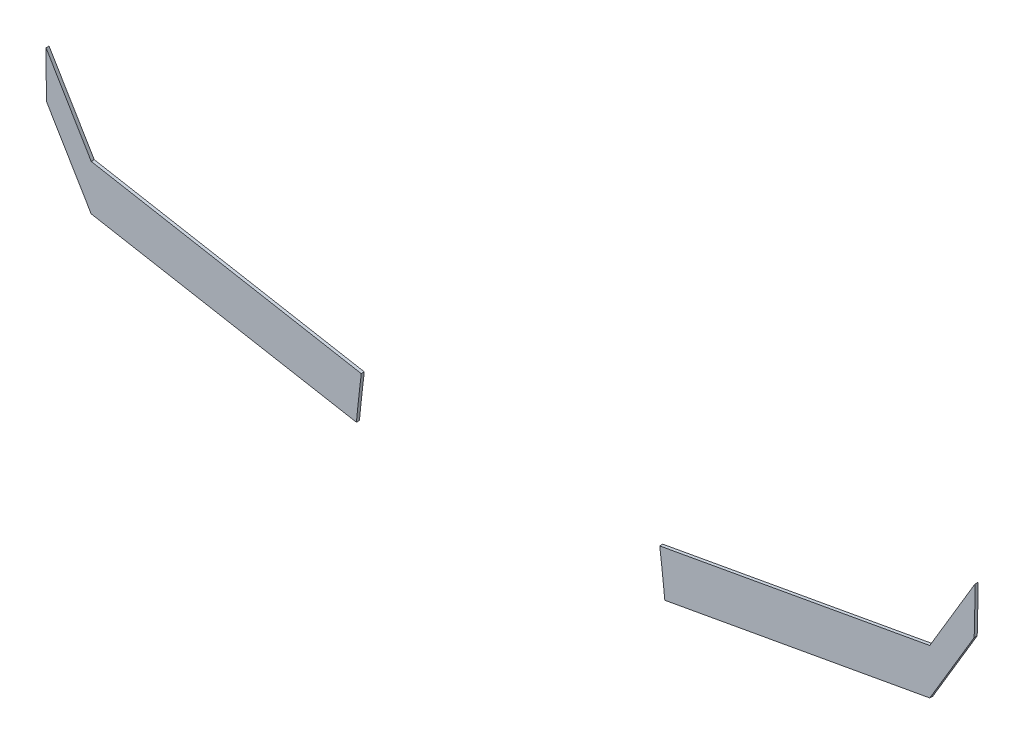
from build123d import *

# Parameters (mm, degrees)
SALIENTE_EXTRUIR1_DEPTH   = 0.1
SALIENTE_EXTRUIR1_2_DEPTH = 0.1


with BuildPart() as part:
    # Model → Saliente-Extruir1 (new body)
    with BuildSketch(Plane.XY):
        with BuildLine():
            ThreePointArc((30.578340462, -24.471121474), (30.493407947, -25.205745326), (30.418644104, -25.941473607))
            Line((30.418644104, -25.941473607), (21.66634164, -24.362151891))
            Line((21.66634164, -24.362151891), (20.197690678, -21.898713264))
            ThreePointArc((20.197690678, -21.898713264), (20.181421827, -21.130225351), (20.176063282, -20.36158393))
            Line((20.176063282, -20.36158393), (21.667447642, -22.862862326))
            Line((21.667447642, -22.862862326), (30.578340462, -24.471121474))
        make_face()
    extrude(amount=SALIENTE_EXTRUIR1_DEPTH)


with BuildPart() as body_2:
    # Model → Saliente-Extruir1 2 (new body)
    with BuildSketch(Plane.XY):
        with BuildLine():
            Line((49.337355198, -24.360837656), (50.80165197, -21.904172006))
            ThreePointArc((50.80165197, -21.904172006), (50.820972205, -21.131859602), (50.828373494, -20.359341031))
            Line((50.828373494, -20.359341031), (49.337355198, -22.860837656))
            Line((49.337355198, -22.860837656), (40.426697834, -24.470400847))
            ThreePointArc((40.426697834, -24.470400847), (40.51513452, -25.204736786), (40.594249402, -25.940135422))
            Line((40.594249402, -25.940135422), (49.337355198, -24.360837656))
        make_face()
    extrude(amount=SALIENTE_EXTRUIR1_2_DEPTH)


solid = Compound([part.part, body_2.part])
